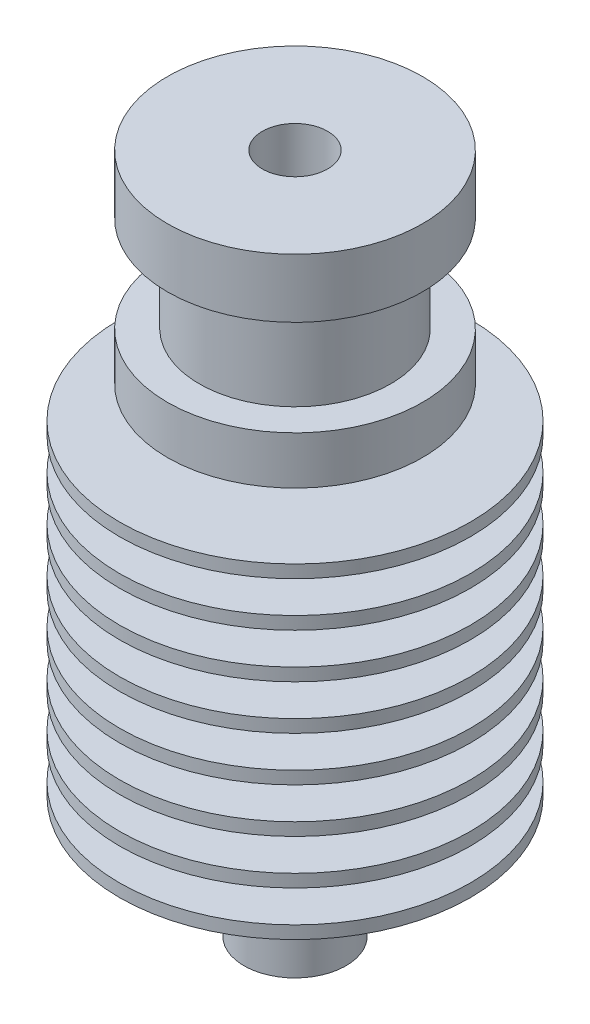
from build123d import *


with BuildPart() as part:
    # Sketch1 → Revolve1 (revolve)
    with BuildSketch(Plane.XY):
        Polygon((2.05, 21.35), (8, 21.35), (8, 17.65), (6, 17.65), (6, 11.65), (8, 11.65), (8, 8.65), (3, 8.65), (3, 6.65), (11, 6.65), (11, 5.85), (3, 5.85), (3, 3.85), (11, 3.85), (11, 3.05), (3, 3.05), (3, 1.05), (11, 1.05), (11, 0.25), (3, 0.25), (3, -1.75), (11, -1.75), (11, -2.55), (3, -2.55), (3, -4.55), (11, -4.55), (11, -5.35), (3, -5.35), (3, -7.35), (11, -7.35), (11, -8.15), (3, -8.15), (3, -10.15), (11, -10.15), (11, -10.95), (3, -10.95), (3, -12.95), (11, -12.95), (11, -13.75), (3.2, -13.75), (2.81308008, -13.75), (2.81308008, -16.35), (3.2, -16.35), (3.2, -21.35), (2.05, -21.35), align=None)
    revolve(axis=Axis((0, -21.35, 0), (0, 1, 0)))


solid = part.part
